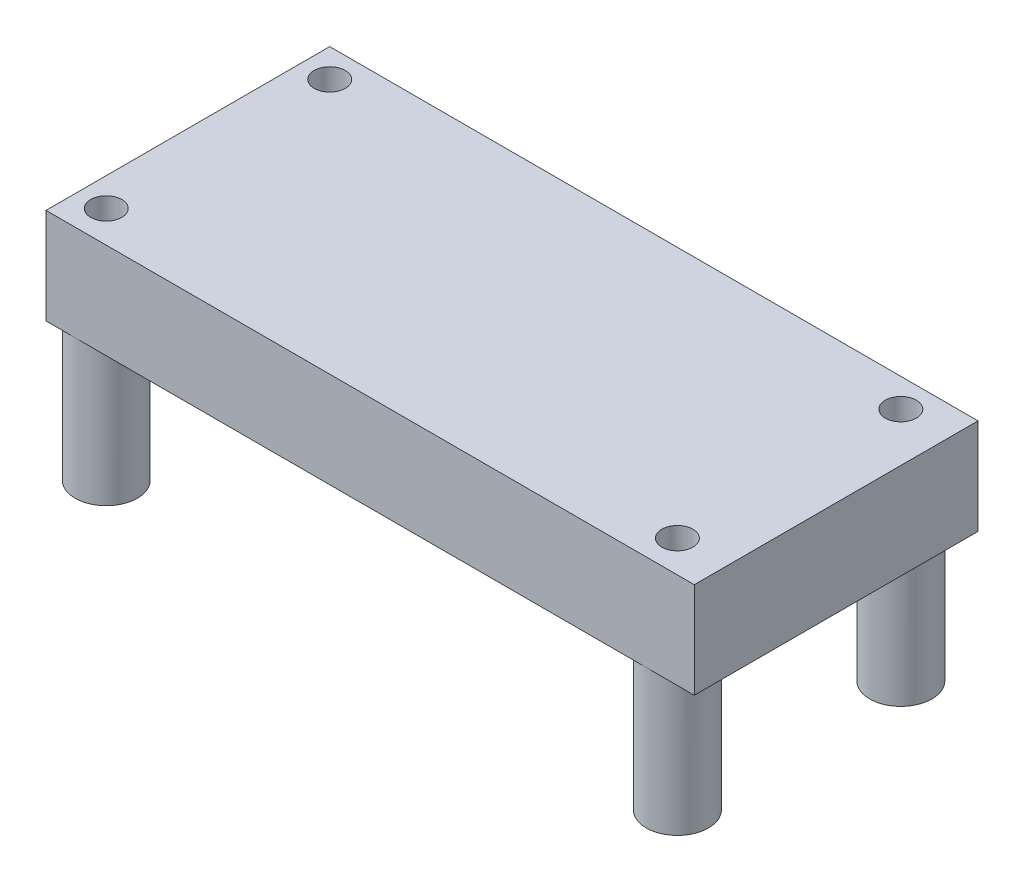
from build123d import *

# Parameters (mm, degrees)
SKETCH1_W           = 52.1
SKETCH1_H           = 22.8
BOSS_EXTRUDE1_DEPTH = 7.6962
SKETCH2_R           = 2.5
BOSS_EXTRUDE2_DEPTH = 11.2268
SKETCH3_R           = 1.25
CUT_EXTRUDE1_DEPTH  = 19.923


with BuildPart() as part:
    # Sketch1 → Boss-Extrude1 (new body)
    with BuildSketch(Plane(origin=(0, 0, 0), x_dir=(1, 0, 0), z_dir=(0, 1, 0))):
        with Locations((9.186055138, 0.076057393)):
            Rectangle(SKETCH1_W, SKETCH1_H)
    extrude(amount=BOSS_EXTRUDE1_DEPTH)

    # Sketch2 → Boss-Extrude2 (add)
    with BuildSketch(Plane.XZ):
        with Locations((-14.577944862, 8.767742607)):
            Circle(SKETCH2_R)
        with Locations((31.319855138, 8.767742607)):
            Circle(SKETCH2_R)
        with Locations((31.319855138, -9.190057393)):
            Circle(SKETCH2_R)
        with Locations((-14.577944862, -9.190057393)):
            Circle(SKETCH2_R)
    extrude(amount=BOSS_EXTRUDE2_DEPTH)

    # Sketch3 → Cut-Extrude1 (cut, through all)
    with BuildSketch(Plane.XZ.offset(11.2268)):
        with Locations((-14.577944862, 8.767742607)):
            Circle(SKETCH3_R)
        with Locations((-14.577944862, -9.190057393)):
            Circle(SKETCH3_R)
        with Locations((31.319855138, -9.190057393)):
            Circle(SKETCH3_R)
        with Locations((31.319855138, 8.767742607)):
            Circle(SKETCH3_R)
    extrude(amount=-CUT_EXTRUDE1_DEPTH, mode=Mode.SUBTRACT)


solid = part.part
